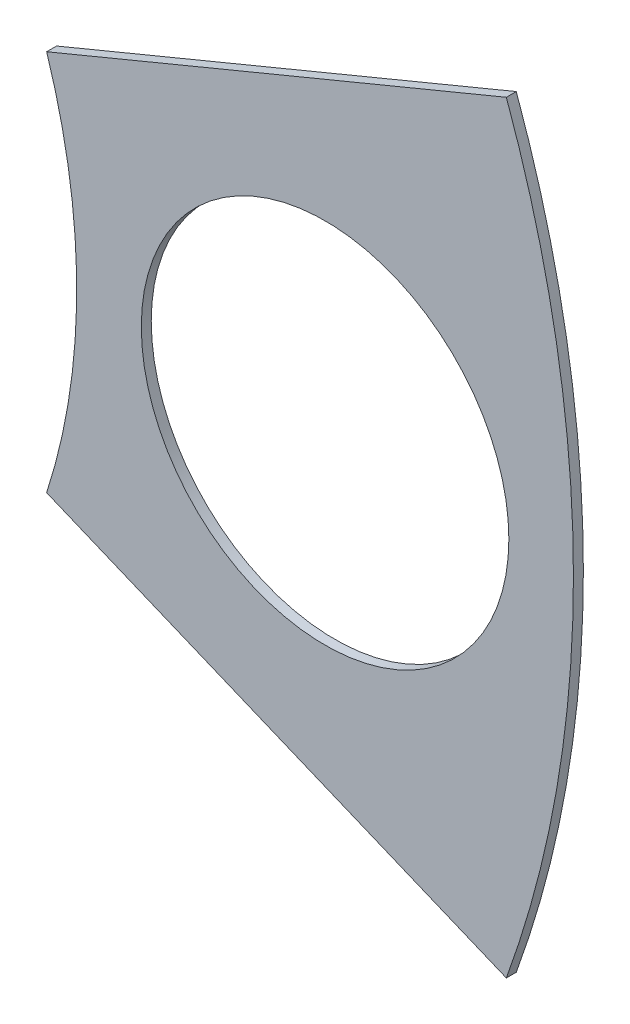
from build123d import *

# Parameters (mm, degrees)
SKETCH4_R           = 28.575
BOSS_EXTRUDE2_DEPTH = 0.254
SKETCH5_R           = 15.875
CUT_EXTRUDE5_DEPTH  = 1.254
SKETCH6_R           = 4.699
CUT_EXTRUDE6_DEPTH  = 1.254
SKETCH8_OUTSIDE_W   = 75.314
SKETCH8_OUTSIDE_H   = 75.314
CUT_EXTRUDE11_DEPTH = 1.254


with BuildPart() as part:
    # Sketch4 → Boss-Extrude2 (new body)
    with BuildSketch(Plane.XY):
        Circle(SKETCH4_R)
    extrude(amount=BOSS_EXTRUDE2_DEPTH)

    # Sketch5 → Cut-Extrude5 (cut, through all)
    with BuildSketch(Plane.XY.offset(0.254)):
        Circle(SKETCH5_R)
    extrude(amount=-CUT_EXTRUDE5_DEPTH, mode=Mode.SUBTRACT)

    # Sketch6 → Cut-Extrude6 (cut, through all)
    with BuildSketch(Plane.XY.offset(0.254)):
        with Locations((22.225, 0)):
            Circle(SKETCH6_R)
    extrude(amount=-CUT_EXTRUDE6_DEPTH, mode=Mode.SUBTRACT)

    # Sketch8 outside → Cut-Extrude11 (cut, through all)
    with BuildSketch(Plane.XY.offset(0.254)):
        Rectangle(SKETCH8_OUTSIDE_W, SKETCH8_OUTSIDE_H)
        with BuildLine():
            Line((15.105587123, 4.88230096), (26.859778778, 9.751046558))
            ThreePointArc((26.859778778, 9.751046558), (28.575, 0), (26.859778778, -9.751046558))
            Line((26.859778778, -9.751046558), (15.105587123, -4.88230096))
            ThreePointArc((15.105587123, -4.88230096), (15.875, 0), (15.105587123, 4.88230096))
        make_face(mode=Mode.SUBTRACT)
    extrude(amount=-CUT_EXTRUDE11_DEPTH, mode=Mode.SUBTRACT)


solid = part.part
